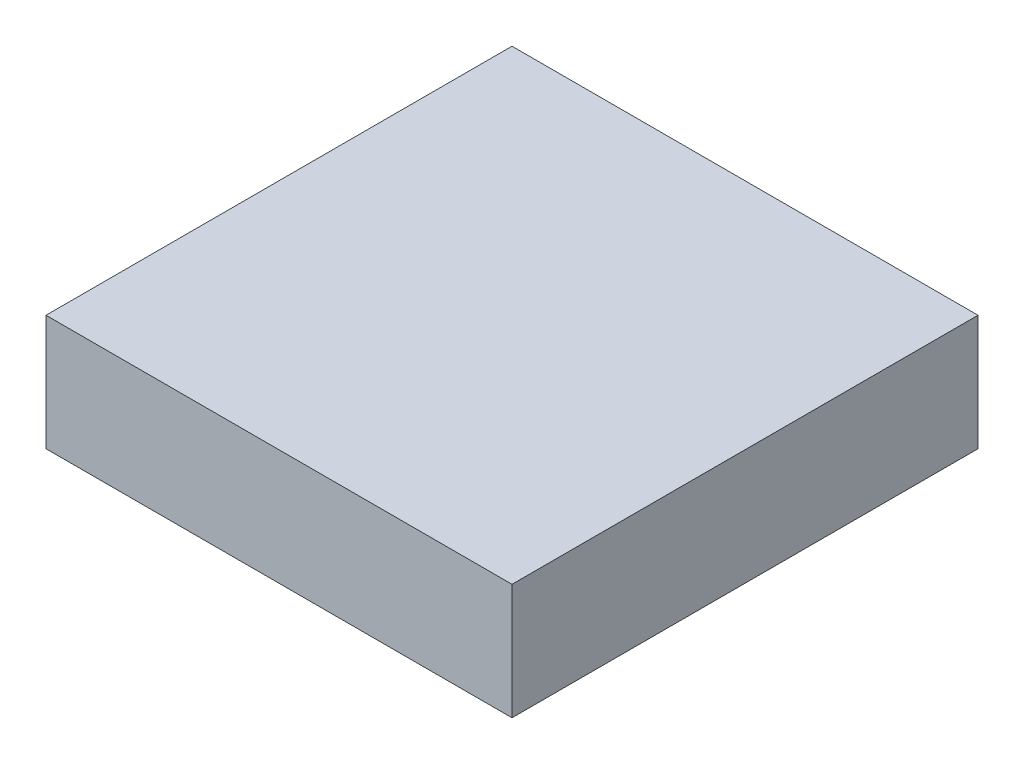
from build123d import *

# Parameters (mm, degrees)
SKETCH2_W           = 4
SKETCH2_H           = 4
BOSS_EXTRUDE1_DEPTH = 0.9925
SKETCH3_W           = 0.25
SKETCH3_H           = 0.35
SKETCH3_W_2         = 0.35
SKETCH3_H_2         = 0.25
BOSS_EXTRUDE2_DEPTH = 0.075


with BuildPart() as part:
    # Sketch2 → Boss-Extrude1 (new body)
    with BuildSketch(Plane(origin=(0, 0, 0), x_dir=(1, 0, 0), z_dir=(0, 1, 0))):
        Rectangle(SKETCH2_W, SKETCH2_H)
    extrude(amount=BOSS_EXTRUDE1_DEPTH)

    # Sketch3 → Boss-Extrude2 (add)
    with BuildSketch(Plane.XZ):
        with Locations((-0.75, 1.705)):
            Rectangle(SKETCH3_W, SKETCH3_H)
        with Locations((-0.25, 1.705)):
            Rectangle(SKETCH3_W, SKETCH3_H)
        with Locations((-1.25, 1.705)):
            Rectangle(SKETCH3_W, SKETCH3_H)
        with Locations((0.25, 1.705)):
            Rectangle(SKETCH3_W, SKETCH3_H)
        with Locations((0.75, 1.705)):
            Rectangle(SKETCH3_W, SKETCH3_H)
        with Locations((1.25, 1.705)):
            Rectangle(SKETCH3_W, SKETCH3_H)
        with Locations((1.25, -1.705)):
            Rectangle(SKETCH3_W, SKETCH3_H)
        with Locations((-1.705, 1.25)):
            Rectangle(SKETCH3_W_2, SKETCH3_H_2)
        with Locations((-1.705, 0.75)):
            Rectangle(SKETCH3_W_2, SKETCH3_H_2)
        with Locations((-1.705, 0.25)):
            Rectangle(SKETCH3_W_2, SKETCH3_H_2)
        with Locations((0.75, -1.705)):
            Rectangle(SKETCH3_W, SKETCH3_H)
        with Locations((0.25, -1.705)):
            Rectangle(SKETCH3_W, SKETCH3_H)
        with Locations((-1.25, -1.705)):
            Rectangle(SKETCH3_W, SKETCH3_H)
        with Locations((-0.75, -1.705)):
            Rectangle(SKETCH3_W, SKETCH3_H)
        with Locations((-0.25, -1.705)):
            Rectangle(SKETCH3_W, SKETCH3_H)
        with Locations((-1.705, -0.75)):
            Rectangle(SKETCH3_W_2, SKETCH3_H_2)
        with Locations((-1.705, -0.25)):
            Rectangle(SKETCH3_W_2, SKETCH3_H_2)
        with Locations((-1.705, -1.25)):
            Rectangle(SKETCH3_W_2, SKETCH3_H_2)
        with Locations((1.705, -1.25)):
            Rectangle(SKETCH3_W_2, SKETCH3_H_2)
        with Locations((1.705, -0.75)):
            Rectangle(SKETCH3_W_2, SKETCH3_H_2)
        with Locations((1.705, -0.25)):
            Rectangle(SKETCH3_W_2, SKETCH3_H_2)
        with Locations((1.705, 0.75)):
            Rectangle(SKETCH3_W_2, SKETCH3_H_2)
        with Locations((1.705, 0.25)):
            Rectangle(SKETCH3_W_2, SKETCH3_H_2)
        with Locations((1.705, 1.25)):
            Rectangle(SKETCH3_W_2, SKETCH3_H_2)
    extrude(amount=BOSS_EXTRUDE2_DEPTH)


solid = part.part
